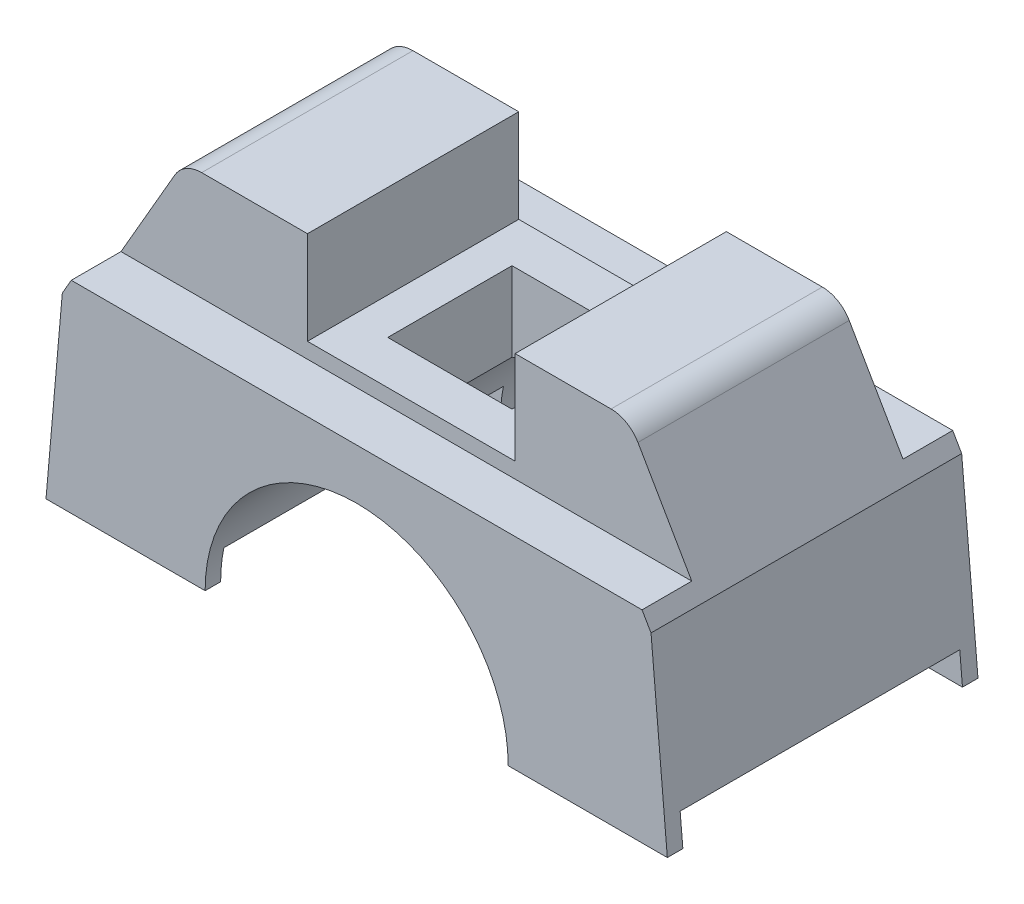
from build123d import *

# Parameters (mm, degrees)
BOSS_EXTRUDE2_DEPTH     = 25
BOSS_EXTRUDE3_DEPTH     = 17
CUT_EXTRUDE1_DEPTH      = 66.954529791
CUT_EXTRUDE1_DEPTH_BACK = 66.954529791
SKETCH3_W               = 20
SKETCH3_H               = 20
CUT_EXTRUDE2_DEPTH      = 76
CUT_EXTRUDE2_DEPTH_BACK = 76


with BuildPart() as part:
    # Sketch1 → Boss-Extrude2 (new, symmetric)
    with BuildSketch(Plane.XY):
        with BuildLine():
            Line((-50, 0), (-24.39, 0))
            ThreePointArc((-24.39, 0), (0, 24.39), (24.39, 0))
            Line((24.39, 0), (50, 0))
            Line((50, 0), (47.375340094, 30))
            Line((47.375340094, 30), (45.931964421, 32.5))
            Line((45.931964421, 32.5), (-45.931964421, 32.5))
            Line((-45.931964421, 32.5), (-47.375340094, 30))
            Line((-47.375340094, 30), (-50, 0))
        make_face()
    extrude(amount=BOSS_EXTRUDE2_DEPTH, both=True)

    # Sketch1_7 → Boss-Extrude3 (add, symmetric)
    with BuildSketch(Plane.XY):
        with BuildLine():
            Line((-37.271710383, 47.5), (-45.931964421, 32.5))
            Line((-45.931964421, 32.5), (45.931964421, 32.5))
            Line((45.931964421, 32.5), (37.271710383, 47.5))
            ThreePointArc((37.271710383, 47.5), (35.441583364, 49.330127019), (32.941583364, 50))
            Line((32.941583364, 50), (17.5, 50))
            Line((17.5, 50), (17.5, 35))
            Line((17.5, 35), (-15.917158097, 35))
            Line((-15.917158097, 35), (-15.917158097, 50))
            Line((-15.917158097, 50), (-32.941583364, 50))
            ThreePointArc((-32.941583364, 50), (-35.441583364, 49.330127019), (-37.271710383, 47.5))
        make_face()
    extrude(amount=BOSS_EXTRUDE3_DEPTH, both=True)

    # Sketch3 → Cut-Extrude1 (cut, two sides: drawn at the far end of the back side and taken through both)
    with BuildSketch(Plane(origin=(0, 35, 0), x_dir=(1, 0, 0), z_dir=(0, 1, 0)).offset(-CUT_EXTRUDE1_DEPTH_BACK)):
        Rectangle(SKETCH3_W, SKETCH3_H)
    extrude(amount=CUT_EXTRUDE1_DEPTH + CUT_EXTRUDE1_DEPTH_BACK, mode=Mode.SUBTRACT)

    # Sketch5 → Cut-Extrude2 (cut, two sides: drawn at the far end of the back side and taken through both)
    with BuildSketch(Plane(origin=(0, 0, 0), x_dir=(0, 0, -1), z_dir=(1, 0, 0)).offset(-CUT_EXTRUDE2_DEPTH_BACK)):
        Polygon((-176.421356237, 0), (-25, 0), (-22.5, 0), (-22.5, 5), (22.5, 5), (22.5, 0), (25, 0), (176.421356237, 0), (176.421356237, -302.842712475), (-176.421356237, -302.842712475), align=None)
    extrude(amount=CUT_EXTRUDE2_DEPTH + CUT_EXTRUDE2_DEPTH_BACK, mode=Mode.SUBTRACT)


solid = part.part
